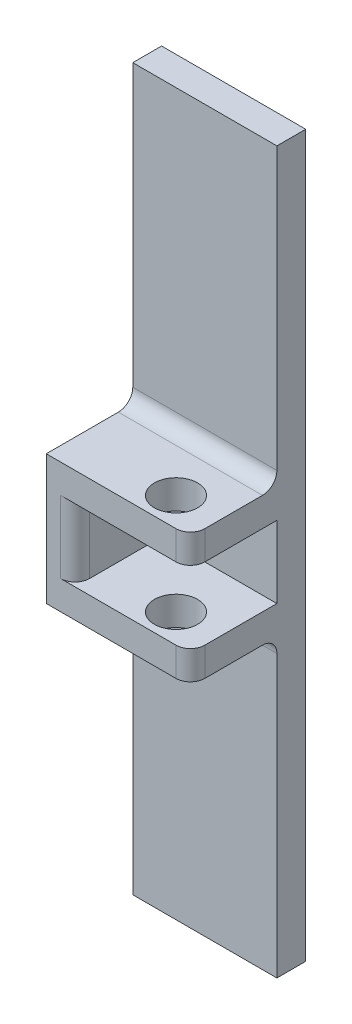
from build123d import *

# Parameters (mm, degrees)
SKETCH1_W           = 10
SKETCH1_H           = 50
BOSS_EXTRUDE1_DEPTH = 3
CHAMFER1_SIZE       = 1
SKETCH2_W           = 10
SKETCH2_H           = 2
BOSS_EXTRUDE2_DEPTH = 6
SKETCH3_R           = 1.5
CUT_EXTRUDE1_DEPTH  = 10
FILLET1_R           = 1
FILLET2_R           = 1
SKETCH4_W           = 6
SKETCH4_H           = 5
BOSS_EXTRUDE3_DEPTH = 2
FILLET3_R           = 1


with BuildPart() as part:
    # Sketch1 → Boss-Extrude1 (new body)
    with BuildSketch(Plane.XY):
        with Locations((5, 25)):
            Rectangle(SKETCH1_W, SKETCH1_H)
    extrude(amount=BOSS_EXTRUDE1_DEPTH)

    # Chamfer1
    chamfer1_edges = [part.edges().sort_by_distance(p)[0] for p in [
        (5, 50, 0),
        (10, 25, 0),
        (5, 0, 0),
        (0, 25, 0),
    ]]
    chamfer(chamfer1_edges, length=CHAMFER1_SIZE)

    # Sketch2 → Boss-Extrude2 (add)
    with BuildSketch(Plane.XY.offset(3)):
        with Locations((5, 28.5)):
            Rectangle(SKETCH2_W, SKETCH2_H)
        with Locations((5, 21.5)):
            Rectangle(SKETCH2_W, SKETCH2_H)
    extrude(amount=BOSS_EXTRUDE2_DEPTH)

    # Sketch3 → Cut-Extrude1 (cut)
    with BuildSketch(Plane.XZ.offset(-20.5)):
        with Locations((7, 7)):
            Circle(SKETCH3_R)
    extrude(amount=-CUT_EXTRUDE1_DEPTH, mode=Mode.SUBTRACT)

    # Fillet1
    fillet1_edges = [part.edges().sort_by_distance(p)[0] for p in [
        (10, 28.5, 9),
        (10, 21.5, 9),
    ]]
    fillet(fillet1_edges, radius=FILLET1_R)

    # Fillet2
    fillet2_edges = [part.edges().sort_by_distance(p)[0] for p in [
        (5, 29.5, 3),
        (5, 20.5, 3),
    ]]
    fillet(fillet2_edges, radius=FILLET2_R)

    # Sketch4 → Boss-Extrude3 (add)
    with BuildSketch(Plane.ZY):
        with Locations((6, 25)):
            Rectangle(SKETCH4_W, SKETCH4_H)
    extrude(amount=-BOSS_EXTRUDE3_DEPTH)

    # Fillet3
    fillet3_edges = [part.edges().sort_by_distance(p)[0] for p in [
        (2, 25, 9),
    ]]
    fillet(fillet3_edges, radius=FILLET3_R)


solid = part.part
